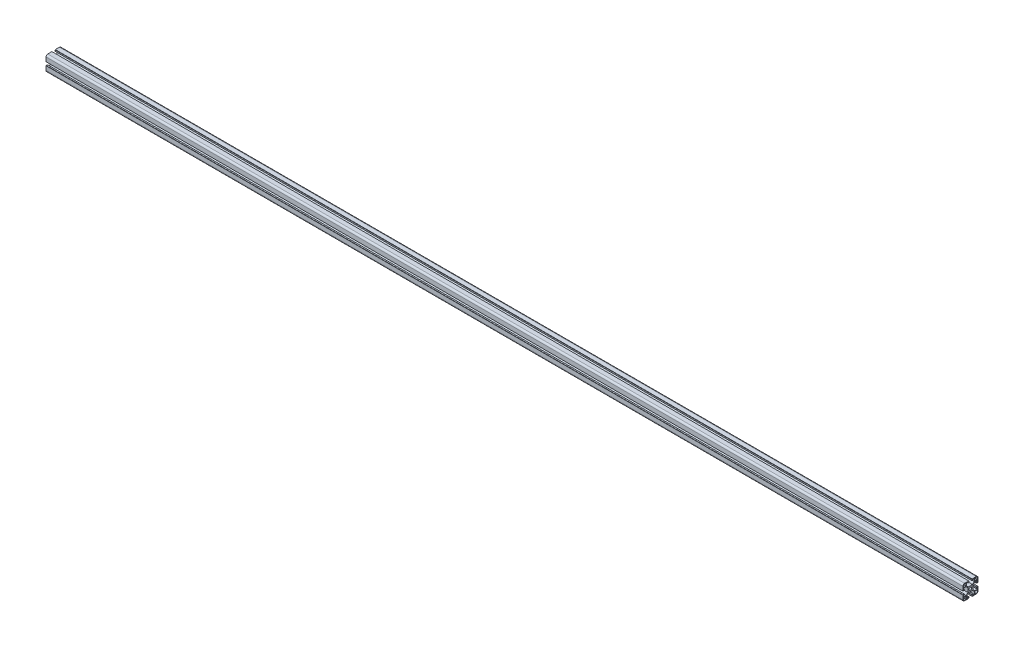
from build123d import *

# Parameters (mm, degrees)
SKETCH_3_R          = 3.4
EXTRUDE_1_DEPTH     = 2421
CUT_EXTRUDE_3_DEPTH = 3297


with BuildPart() as part:
    # 草图3 → 凸台-拉伸1 (new body)
    with BuildSketch(Plane(origin=(0, 0, 0), x_dir=(0, 0, -1), z_dir=(1, 0, 0))):
        with BuildLine():
            Line((-15.5, -20), (-4.5, -20))
            Line((-4.5, -20), (-4.5, -19.5))
            Line((-4.5, -19.5), (-4.1, -19.5))
            Line((-4.1, -19.5), (-4.1, -16.2))
            Line((-4.1, -16.2), (-6.4, -16.2))
            Line((-6.4, -16.2), (-6.4, -18.2))
            Line((-6.4, -18.2), (-10.25, -18.2))
            Line((-10.25, -18.2), (-10.25, -11.522792206))
            Line((-10.25, -11.522792206), (-5.479130441, -6.751922647))
            Line((-5.479130441, -6.751922647), (5.479130441, -6.751922647))
            Line((5.479130441, -6.751922647), (10.25, -11.522792206))
            Line((10.25, -11.522792206), (10.25, -18.2))
            Line((10.25, -18.2), (6.4, -18.2))
            Line((6.4, -18.2), (6.4, -16.2))
            Line((6.4, -16.2), (4.1, -16.2))
            Line((4.1, -16.2), (4.1, -19.5))
            Line((4.1, -19.5), (4.5, -19.5))
            Line((4.5, -19.5), (4.5, -20))
            Line((4.5, -20), (15.5, -20))
            ThreePointArc((15.5, -20), (18.681980515, -18.681980515), (20, -15.5))
            Line((20, -15.5), (20, -4.5))
            Line((20, -4.5), (19.5, -4.5))
            Line((19.5, -4.5), (19.5, -4.1))
            Line((19.5, -4.1), (16.2, -4.1))
            Line((16.2, -4.1), (16.2, -6.4))
            Line((16.2, -6.4), (18.2, -6.4))
            Line((18.2, -6.4), (18.2, -10.25))
            Line((18.2, -10.25), (11.522792206, -10.25))
            Line((11.522792206, -10.25), (6.751922647, -5.479130441))
            Line((6.751922647, -5.479130441), (6.751922647, 5.479130441))
            Line((6.751922647, 5.479130441), (11.522792206, 10.25))
            Line((11.522792206, 10.25), (18.2, 10.25))
            Line((18.2, 10.25), (18.2, 6.4))
            Line((18.2, 6.4), (16.2, 6.4))
            Line((16.2, 6.4), (16.2, 4.1))
            Line((16.2, 4.1), (19.5, 4.1))
            Line((19.5, 4.1), (19.5, 4.5))
            Line((19.5, 4.5), (20, 4.5))
            Line((20, 4.5), (20, 15.5))
            ThreePointArc((20, 15.5), (18.681980515, 18.681980515), (15.5, 20))
            Line((15.5, 20), (4.5, 20))
            Line((4.5, 20), (4.5, 19.5))
            Line((4.5, 19.5), (4.1, 19.5))
            Line((4.1, 19.5), (4.1, 16.2))
            Line((4.1, 16.2), (6.4, 16.2))
            Line((6.4, 16.2), (6.4, 18.2))
            Line((6.4, 18.2), (10.25, 18.2))
            Line((10.25, 18.2), (10.25, 11.522792206))
            Line((10.25, 11.522792206), (5.479130441, 6.751922647))
            Line((5.479130441, 6.751922647), (-5.479130441, 6.751922647))
            Line((-5.479130441, 6.751922647), (-10.25, 11.522792206))
            Line((-10.25, 11.522792206), (-10.25, 18.2))
            Line((-10.25, 18.2), (-6.4, 18.2))
            Line((-6.4, 18.2), (-6.4, 16.2))
            Line((-6.4, 16.2), (-4.1, 16.2))
            Line((-4.1, 16.2), (-4.1, 19.5))
            Line((-4.1, 19.5), (-4.5, 19.5))
            Line((-4.5, 19.5), (-4.5, 20))
            Line((-4.5, 20), (-15.5, 20))
            ThreePointArc((-15.5, 20), (-18.681980515, 18.681980515), (-20, 15.5))
            Line((-20, 15.5), (-20, 4.5))
            Line((-20, 4.5), (-19.5, 4.5))
            Line((-19.5, 4.5), (-19.5, 4.1))
            Line((-19.5, 4.1), (-16.2, 4.1))
            Line((-16.2, 4.1), (-16.2, 6.4))
            Line((-16.2, 6.4), (-18.2, 6.4))
            Line((-18.2, 6.4), (-18.2, 10.25))
            Line((-18.2, 10.25), (-11.522792206, 10.25))
            Line((-11.522792206, 10.25), (-6.751922647, 5.479130441))
            Line((-6.751922647, 5.479130441), (-6.751922647, -5.479130441))
            Line((-6.751922647, -5.479130441), (-11.522792206, -10.25))
            Line((-11.522792206, -10.25), (-18.2, -10.25))
            Line((-18.2, -10.25), (-18.2, -6.4))
            Line((-18.2, -6.4), (-16.2, -6.4))
            Line((-16.2, -6.4), (-16.2, -4.1))
            Line((-16.2, -4.1), (-19.5, -4.1))
            Line((-19.5, -4.1), (-19.5, -4.5))
            Line((-19.5, -4.5), (-20, -4.5))
            Line((-20, -4.5), (-20, -15.5))
            ThreePointArc((-20, -15.5), (-18.681980515, -18.681980515), (-15.5, -20))
        make_face()
        Circle(SKETCH_3_R, mode=Mode.SUBTRACT)
    extrude(amount=EXTRUDE_1_DEPTH)

    # 草图4 → 切除-拉伸3 (cut)
    with BuildSketch(Plane(origin=(2421, -20, 15.5), x_dir=(0, 0, 1), z_dir=(-1, 0, 0))):
        with BuildLine():
            Line((-3.75, 31.75), (3, 31.75))
            Line((3, 31.75), (3, 35.5))
            ThreePointArc((3, 35.5), (2.121320344, 37.621320344), (0, 38.5))
            Line((0, 38.5), (-3.75, 38.5))
            Line((-3.75, 38.5), (-3.75, 31.75))
        make_face()
        with BuildLine():
            Line((-3.75, 8.25), (-3.75, 1.5))
            Line((-3.75, 1.5), (0, 1.5))
            ThreePointArc((0, 1.5), (2.121320344, 2.378679656), (3, 4.5))
            Line((3, 4.5), (3, 8.25))
            Line((3, 8.25), (-3.75, 8.25))
        make_face()
        with BuildLine():
            Line((-27.25, 8.25), (-34, 8.25))
            Line((-34, 8.25), (-34, 4.5))
            ThreePointArc((-34, 4.5), (-33.121320344, 2.378679656), (-31, 1.5))
            Line((-31, 1.5), (-27.25, 1.5))
            Line((-27.25, 1.5), (-27.25, 8.25))
        make_face()
        with BuildLine():
            Line((-27.25, 31.75), (-27.25, 38.5))
            Line((-27.25, 38.5), (-31, 38.5))
            ThreePointArc((-31, 38.5), (-33.121320344, 37.621320344), (-34, 35.5))
            Line((-34, 35.5), (-34, 31.75))
            Line((-34, 31.75), (-27.25, 31.75))
        make_face()
    extrude(amount=CUT_EXTRUDE_3_DEPTH, mode=Mode.SUBTRACT)


solid = part.part
